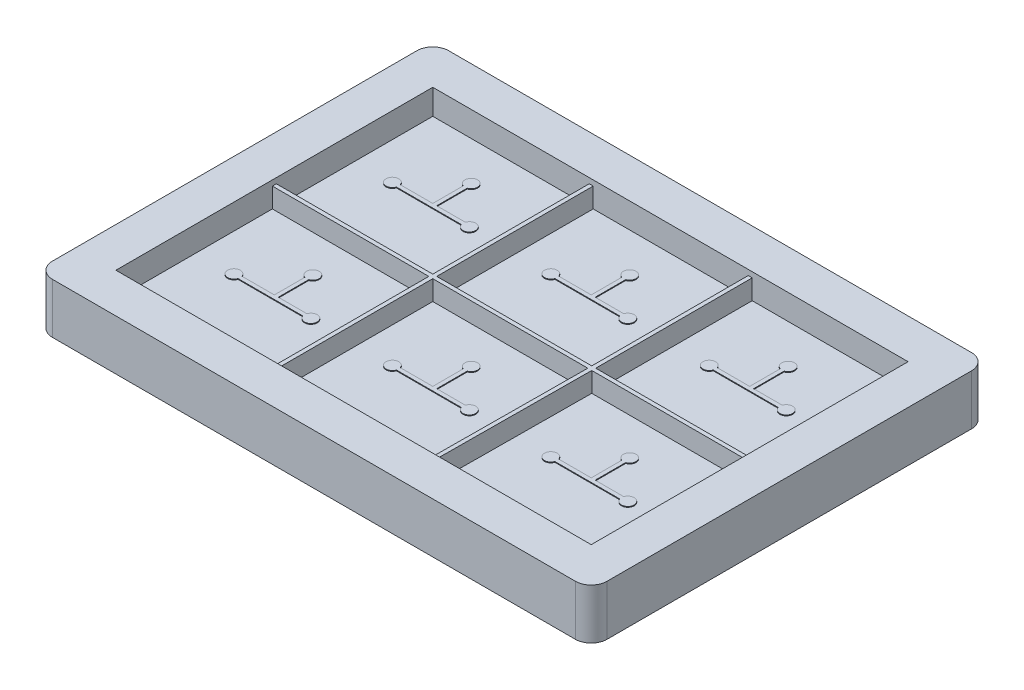
from build123d import *

# Parameters (mm, degrees)
SKETCH1_W            = 70
SKETCH1_H            = 50
BOSS_EXTRUDE1_DEPTH  = 6.35
SKETCH2_W            = 60
SKETCH2_H            = 40
CUT_EXTRUDE1_DEPTH   = 3.175
DIVIDERS_DEPTH       = 2.5
SKETCH11_W           = 0.5
SKETCH11_H           = 0.5
SKETCH11_W_2         = 4.089905709
SKETCH11_W_3         = 3.608523714
SKETCH11_H_2         = 3.849214712
BOSS_EXTRUDE3_DEPTH  = 0.1
LPATTERN1_COUNT      = 3
LPATTERN1_PITCH      = 20
LPATTERN1_COUNT_DIR2 = 2
LPATTERN1_PITCH_DIR2 = 20
FILLET1_R            = 2


with BuildPart() as part:
    # Sketch1 → Boss-Extrude1 (new body)
    with BuildSketch(Plane(origin=(0, 0, 0), x_dir=(1, 0, 0), z_dir=(0, 1, 0))):
        Rectangle(SKETCH1_W, SKETCH1_H)
    extrude(amount=BOSS_EXTRUDE1_DEPTH)

    # Sketch2 → Cut-Extrude1 (cut)
    with BuildSketch(Plane(origin=(0, 6.35, 0), x_dir=(1, 0, 0), z_dir=(0, 1, 0))):
        Rectangle(SKETCH2_W, SKETCH2_H)
    extrude(amount=-CUT_EXTRUDE1_DEPTH, mode=Mode.SUBTRACT)

    # Sketch10 → Dividers (add)
    with BuildSketch(Plane(origin=(0, 3.175, 0), x_dir=(1, 0, 0), z_dir=(0, 1, 0))):
        Polygon((-10.25, -0.25), (-10.25, -20), (-9.75, -20), (-9.75, -0.25), (9.818560524, -0.25), (9.681439476, -20), (10.181439476, -20), (10.318560524, -0.25), (30, -0.25), (30, 0.25), (10.318560524, 0.25), (10.318560524, 20), (9.818560524, 20), (9.818560524, 0.25), (-9.75, 0.25), (-9.75, 20), (-10.25, 20), (-10.25, 0.25), (-30, 0.25), (-30, -0.25), align=None)
    extrude(amount=DIVIDERS_DEPTH)

    # Sketch11 → Boss-Extrude3 (add)
    with BuildSketch(Plane(origin=(0, 3.175, 0), x_dir=(1, 0, 0), z_dir=(0, 1, 0))):
        with Locations((-20.125, 10.125)):
            Rectangle(SKETCH11_W, SKETCH11_H)
        with Locations((-22.419952854, 10.125)):
            Rectangle(SKETCH11_W_2, SKETCH11_H)
        with Locations((-18.070738143, 10.125)):
            Rectangle(SKETCH11_W_3, SKETCH11_H)
        with BuildLine():
            ThreePointArc((-24.464905709, 10.375), (-26.024839917, 10.125), (-24.464905709, 9.875))
            Line((-24.464905709, 9.875), (-24.464905709, 10.375))
        make_face()
        with Locations((-20.125, 12.299607356)):
            Rectangle(SKETCH11_W, SKETCH11_H_2)
        with BuildLine():
            Line((-16.266476286, 10.375), (-16.266476286, 9.875))
            ThreePointArc((-16.266476286, 9.875), (-14.706542078, 10.125), (-16.266476286, 10.375))
        make_face()
        with BuildLine():
            ThreePointArc((-19.875, 14.224214712), (-20.125, 15.784148919), (-20.375, 14.224214712))
            Line((-20.375, 14.224214712), (-19.875, 14.224214712))
        make_face()
    boss_extrude3 = extrude(amount=BOSS_EXTRUDE3_DEPTH)

    # LPattern1: Boss-Extrude3 3 × 2
    with Locations(*[(i * LPATTERN1_PITCH, 0, j * LPATTERN1_PITCH_DIR2) for i in range(LPATTERN1_COUNT) for j in range(LPATTERN1_COUNT_DIR2) if (i, j) != (0, 0)]):
        add(boss_extrude3)

    # Fillet1
    fillet1_edges = [part.edges().sort_by_distance(p)[0] for p in [
        (35, 3.175, 25),
        (-35, 3.175, 25),
        (-35, 3.175, -25),
        (35, 3.175, -25),
    ]]
    fillet(fillet1_edges, radius=FILLET1_R)


solid = part.part
